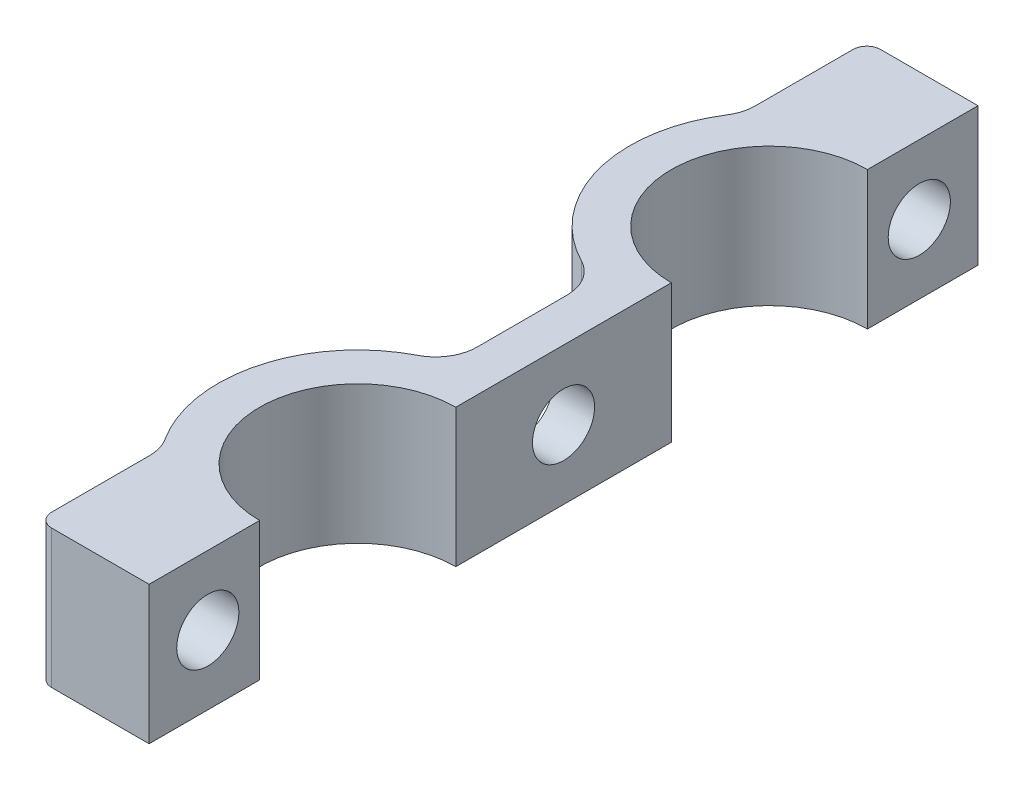
from build123d import *

# Parameters (mm, degrees)
EXTRUDE_1_DEPTH          = 10
EXTRUDE_2_DEPTH          = 10
SKETCH_3_R               = 2.25
CUT_EXTRUDE_1_DEPTH      = 5.049845
CUT_EXTRUDE_1_DEPTH_BACK = 4
SKETCH_4_R               = 2.25
CUT_EXTRUDE_2_DEPTH      = 4
FILLET_1_R               = 3
FILLET_2_R               = 1


with BuildPart() as part:
    # Эскиз1 → Бобышка-Вытянуть1 (new body)
    with BuildSketch(Plane(origin=(0, 0, 0), x_dir=(1, 0, 0), z_dir=(0, 1, 0))):
        with BuildLine():
            Line((0, 0), (0, 8))
            ThreePointArc((0, 8), (-7.1, 15.1), (0, 22.2))
            Line((0, 22.2), (0, 37.8))
            ThreePointArc((0, 37.8), (-7.1, 44.9), (0, 52))
            Line((0, 52), (0, 60))
            Line((0, 60), (-3, 60))
            Line((-3, 60), (-3, 54.544169223))
            ThreePointArc((-3, 54.544169223), (-10.1, 44.9), (-3, 35.255830777))
            Line((-3, 35.255830777), (-3, 24.744169223))
            ThreePointArc((-3, 24.744169223), (-10.1, 15.1), (-3, 5.455830777))
            Line((-3, 5.455830777), (-3, 0))
            Line((-3, 0), (0, 0))
        make_face()
    extrude(amount=EXTRUDE_1_DEPTH)

    # Эскиз2 → Бобышка-Вытянуть2 (add)
    with BuildSketch(Plane(origin=(0, 10, 0), x_dir=(1, 0, 0), z_dir=(0, 1, 0))):
        with BuildLine():
            Line((-3, 60), (-8.049844719, 60))
            Line((-8.049844719, 60), (-8.049844719, 51))
            ThreePointArc((-8.049844719, 51), (-5.802159163, 53.167100402), (-3, 54.544169223))
            Line((-3, 54.544169223), (-3, 60))
        make_face()
        with BuildLine():
            Line((-3, 0), (-3, 5.455830777))
            ThreePointArc((-3, 5.455830777), (-5.802159163, 6.832899598), (-8.049844719, 9))
            Line((-8.049844719, 9), (-8.049844719, 0))
            Line((-8.049844719, 0), (-3, 0))
        make_face()
    extrude(amount=-EXTRUDE_2_DEPTH)

    # Эскиз3 → Вырез-Вытянуть1 (cut, two sides)
    with BuildSketch(Plane.ZY.offset(3)) as cut_extrude_1_sk:
        with Locations((-55.75, 5)):
            Circle(SKETCH_3_R)
        with Locations((-4.25, 5)):
            Circle(SKETCH_3_R)
    extrude(amount=CUT_EXTRUDE_1_DEPTH, mode=Mode.SUBTRACT)
    extrude(cut_extrude_1_sk.sketch, amount=-CUT_EXTRUDE_1_DEPTH_BACK, mode=Mode.SUBTRACT)

    # Эскиз4 → Вырез-Вытянуть2 (cut, through all)
    with BuildSketch(Plane.ZY.offset(3)):
        with Locations((-30, 5)):
            Circle(SKETCH_4_R)
    extrude(amount=-CUT_EXTRUDE_2_DEPTH, mode=Mode.SUBTRACT)

    # Скругление1
    fillet_1_edges = [part.edges().sort_by_distance(p)[0] for p in [
        (-3, 5, -24.744169223),
        (-3, 5, -35.255830777),
        (-8.049844719, 5, -51),
        (-8.049844719, 5, -9),
    ]]
    fillet(fillet_1_edges, radius=FILLET_1_R)

    # Скругление2
    fillet_2_edges = [part.edges().sort_by_distance(p)[0] for p in [
        (-8.049844719, 5, -60),
        (-8.049844719, 5, 0),
    ]]
    fillet(fillet_2_edges, radius=FILLET_2_R)


solid = part.part
